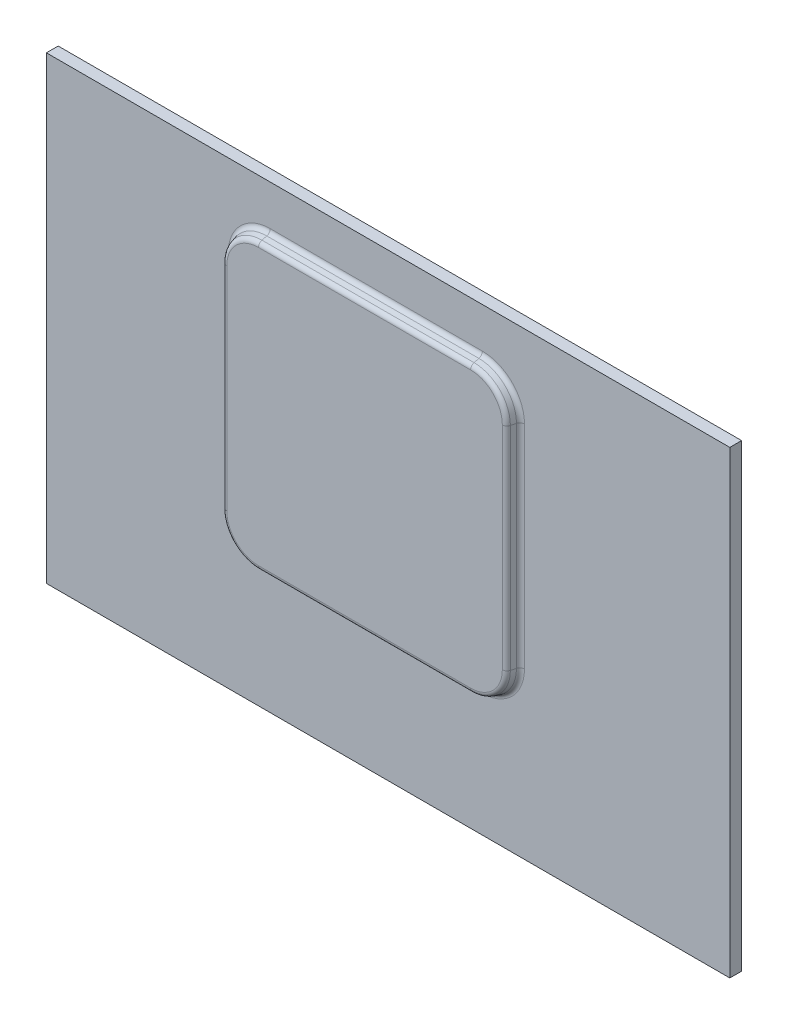
from build123d import *

# Parameters (mm, degrees)
SKETCH_1_W      = 290
SKETCH_1_H      = 195
EXTRUDE_1_DEPTH = 5
SKETCH_2_W      = 120
SKETCH_2_H      = 120
EXTRUDE_2_DEPTH = 5
FILLET_1_R      = 15
DRAFT_1_ANGLE   = 15
FILLET_2_R      = 2


with BuildPart() as part:
    # 草图1 → 凸台-拉伸1 (new body)
    with BuildSketch(Plane.XY):
        Rectangle(SKETCH_1_W, SKETCH_1_H)
    extrude(amount=EXTRUDE_1_DEPTH)

    # 草图2 → 凸台-拉伸2 (add)
    with BuildSketch(Plane.XY.offset(5)):
        with Locations((-5, 17.5)):
            Rectangle(SKETCH_2_W, SKETCH_2_H)
    extrude(amount=EXTRUDE_2_DEPTH)

    # 圆角1
    fillet_1_edges = [part.edges().sort_by_distance(p)[0] for p in [
        (-65, 77.5, 7.5),
        (-65, -42.5, 7.5),
        (55, -42.5, 7.5),
        (55, 77.5, 7.5),
    ]]
    fillet(fillet_1_edges, radius=FILLET_1_R)

    # 拔模1
    draft_1_faces = [part.faces().sort_by_distance(p)[0] for p in [
        (-65, 17.5, 7.5),
        (-60.606601718, 73.106601718, 7.5),
        (-5, 77.5, 7.5),
        (50.606601718, 73.106601718, 7.5),
        (55, 17.5, 7.5),
        (50.606601718, -38.106601718, 7.5),
        (-5, -42.5, 7.5),
        (-60.606601718, -38.106601718, 7.5),
    ]]
    draft(draft_1_faces, Plane.XY.offset(10), DRAFT_1_ANGLE)

    # 圆角2
    fillet_2_edges = [part.edges().sort_by_distance(p)[0] for p in [
        (-5, -43.839745962, 5),
        (-5, -42.5, 10),
        (-66.339745962, 17.5, 5),
        (-65, 17.5, 10),
        (55, 17.5, 10),
        (-5, 77.5, 10),
        (50.606601718, 73.106601718, 10),
        (-60.606601718, 73.106601718, 10),
        (50.606601718, -38.106601718, 10),
        (-60.606601718, -38.106601718, 10),
        (56.339745962, 17.5, 5),
        (-5, 78.839745962, 5),
        (-61.553945173, -39.053945173, 5),
        (51.553945173, -39.053945173, 5),
        (-61.553945173, 74.053945173, 5),
        (51.553945173, 74.053945173, 5),
    ]]
    fillet(fillet_2_edges, radius=FILLET_2_R)


solid = part.part
